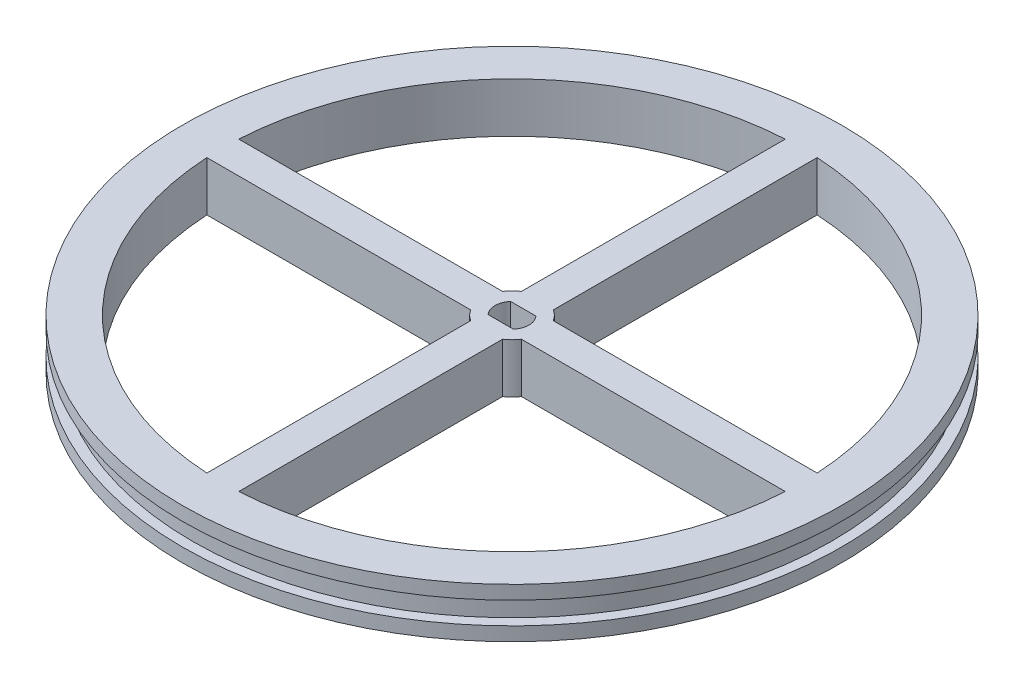
from build123d import *

# Parameters (mm, degrees)
SKETCH1_R           = 52.3875
SKETCH1_R_2         = 50.8
BOSS_EXTRUDE1_DEPTH = 7.9
CUT_EXTRUDE1_START  = 3.95
SKETCH1_3_R         = 52.3875
SKETCH1_3_R_2       = 50.8
CUT_EXTRUDE1_DEPTH  = 1.7653


with BuildPart() as part:
    # Sketch1 → Boss-Extrude1 (new body)
    with BuildSketch(Plane(origin=(0, 0, 0), x_dir=(1, 0, 0), z_dir=(0, 1, 0))):
        with Locations(Location((0, 0, 0), (0, 0, 270))):
            Circle(SKETCH1_R)
        Circle(SKETCH1_R_2, mode=Mode.SUBTRACT)
        Circle(SKETCH1_R_2)
        with BuildLine():
            Line((-2.54, 4.028623369), (-2.54, 45.967377631))
            ThreePointArc((-2.54, 45.967377631), (-32.553428439, 32.553428439), (-45.967377631, 2.54))
            Line((-45.967377631, 2.54), (-4.028623369, 2.54))
            ThreePointArc((-4.028623369, 2.54), (-3.367596045, 3.367596045), (-2.54, 4.028623369))
        make_face(mode=Mode.SUBTRACT)
        with BuildLine():
            Line((4.028623369, 2.54), (45.967377631, 2.54))
            ThreePointArc((45.967377631, 2.54), (32.553428439, 32.553428439), (2.54, 45.967377631))
            Line((2.54, 45.967377631), (2.54, 4.028623369))
            ThreePointArc((2.54, 4.028623369), (3.367596045, 3.367596045), (4.028623369, 2.54))
        make_face(mode=Mode.SUBTRACT)
        with BuildLine():
            Line((2.54, -4.028623369), (2.54, -45.967377631))
            ThreePointArc((2.54, -45.967377631), (32.553428439, -32.553428439), (45.967377631, -2.54))
            Line((45.967377631, -2.54), (4.028623369, -2.54))
            ThreePointArc((4.028623369, -2.54), (3.367596045, -3.367596045), (2.54, -4.028623369))
        make_face(mode=Mode.SUBTRACT)
        with BuildLine():
            ThreePointArc((2.01246118, -1.8), (2.7, 0), (2.01246118, 1.8))
            Line((2.01246118, 1.8), (-2.01246118, 1.8))
            ThreePointArc((-2.01246118, 1.8), (-2.7, 0), (-2.01246118, -1.8))
            Line((-2.01246118, -1.8), (2.01246118, -1.8))
        make_face(mode=Mode.SUBTRACT)
        with BuildLine():
            ThreePointArc((-45.967377631, -2.54), (-32.553428439, -32.553428439), (-2.54, -45.967377631))
            Line((-2.54, -45.967377631), (-2.54, -4.028623369))
            ThreePointArc((-2.54, -4.028623369), (-3.367596045, -3.367596045), (-4.028623369, -2.54))
            Line((-4.028623369, -2.54), (-45.967377631, -2.54))
        make_face(mode=Mode.SUBTRACT)
    extrude(amount=BOSS_EXTRUDE1_DEPTH)

    # Sketch1_3 → Cut-Extrude1 (cut, symmetric)
    with BuildSketch(Plane(origin=(0, 0, 0), x_dir=(1, 0, 0), z_dir=(0, 1, 0)).offset(CUT_EXTRUDE1_START)):
        with Locations(Location((0, 0, 0), (0, 0, 270))):
            Circle(SKETCH1_3_R)
        with Locations(Location((0, 0, 0), (0, 0, 270))):
            Circle(SKETCH1_3_R_2, mode=Mode.SUBTRACT)
    extrude(amount=CUT_EXTRUDE1_DEPTH, both=True, mode=Mode.SUBTRACT)


solid = part.part
